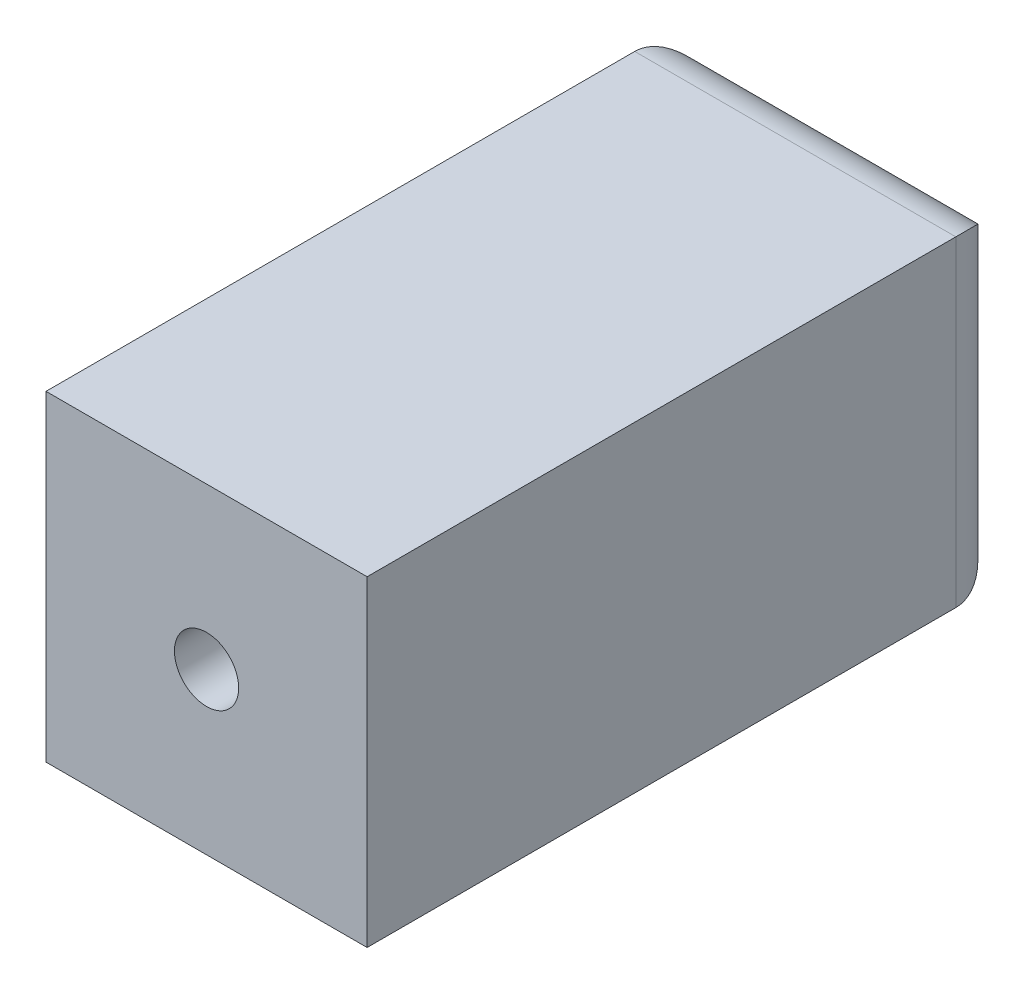
from build123d import *

# Parameters (mm, degrees)
SKETCH1_W             = 15
SKETCH1_H             = 15
BOSS_EXTRUDE1_DEPTH   = 30
FILLET2_R             = 2.5
M3X0_5_TAPPED_HOLE1_D = 3
SKETCH5_R             = 3
CUT_EXTRUDE1_DEPTH    = 27


with BuildPart() as part:
    # Sketch1 → Boss-Extrude1 (new body)
    with BuildSketch(Plane.XY):
        with Locations((7.5, 7.5)):
            Rectangle(SKETCH1_W, SKETCH1_H)
    extrude(amount=BOSS_EXTRUDE1_DEPTH)

    # Fillet2
    fillet2_edges = [part.edges().sort_by_distance(p)[0] for p in [
        (7.5, 15, 0),
        (15, 7.5, 0),
        (7.5, 0, 0),
        (0, 7.5, 0),
    ]]
    fillet(fillet2_edges, radius=FILLET2_R)

    # M3x0.5 Tapped Hole1 (through all)
    with Locations(Plane(origin=(0, 0, 0), x_dir=(-1, 0, 0), z_dir=(0, 0, -1))):
        with Locations((-7.5, 7.5)):
            Hole(M3X0_5_TAPPED_HOLE1_D / 2)

    # Sketch5 → Cut-Extrude1 (cut)
    with BuildSketch(Plane(origin=(0, 0, 0), x_dir=(-1, 0, 0), z_dir=(0, 0, -1))):
        with Locations((-7.5, 7.5)):
            Circle(SKETCH5_R)
    extrude(amount=-CUT_EXTRUDE1_DEPTH, mode=Mode.SUBTRACT)


solid = part.part
